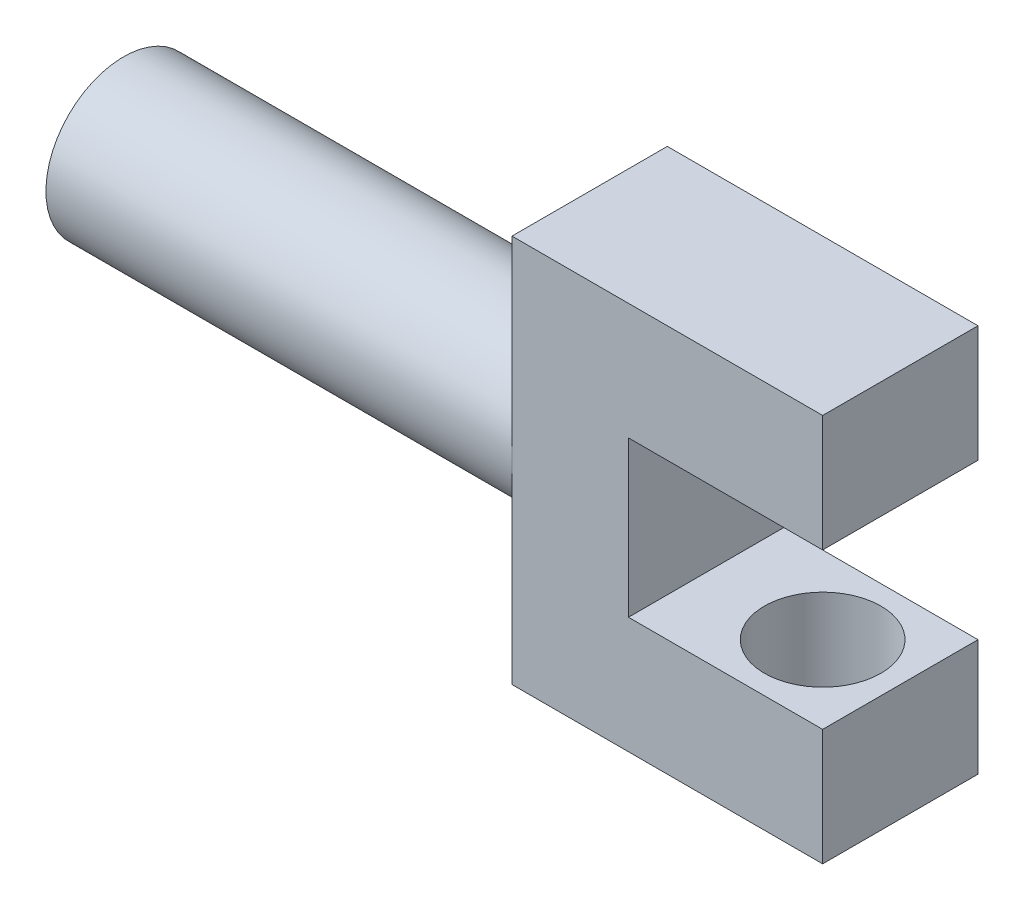
from build123d import *

# Parameters (mm, degrees)
BOSS_EXTRUDE1_DEPTH     = 10
SKETCH3_R               = 10
BOSS_EXTRUDE2_DEPTH     = 60
SKETCH4_R               = 7.5
CUT_EXTRUDE1_DEPTH      = 32
CUT_EXTRUDE1_DEPTH_BACK = 12


with BuildPart() as part:
    # Sketch2 → Boss-Extrude1 (new body, symmetric)
    with BuildSketch(Plane.XY):
        Polygon((0, 25), (0, -25), (40, -25), (40, -10), (15, -10), (15, 10), (40, 10), (40, 25), align=None)
    extrude(amount=BOSS_EXTRUDE1_DEPTH, both=True)

    # Sketch3 → Boss-Extrude2 (add)
    with BuildSketch(Plane.ZY):
        Circle(SKETCH3_R)
    extrude(amount=BOSS_EXTRUDE2_DEPTH)

    # Sketch4 → Cut-Extrude1 (cut, two sides)
    with BuildSketch(Plane.XZ.offset(-10)) as cut_extrude1_sk:
        with Locations((30, 0)):
            Circle(SKETCH4_R)
    extrude(amount=CUT_EXTRUDE1_DEPTH, mode=Mode.SUBTRACT)
    extrude(cut_extrude1_sk.sketch, amount=-CUT_EXTRUDE1_DEPTH_BACK, mode=Mode.SUBTRACT)


solid = part.part
